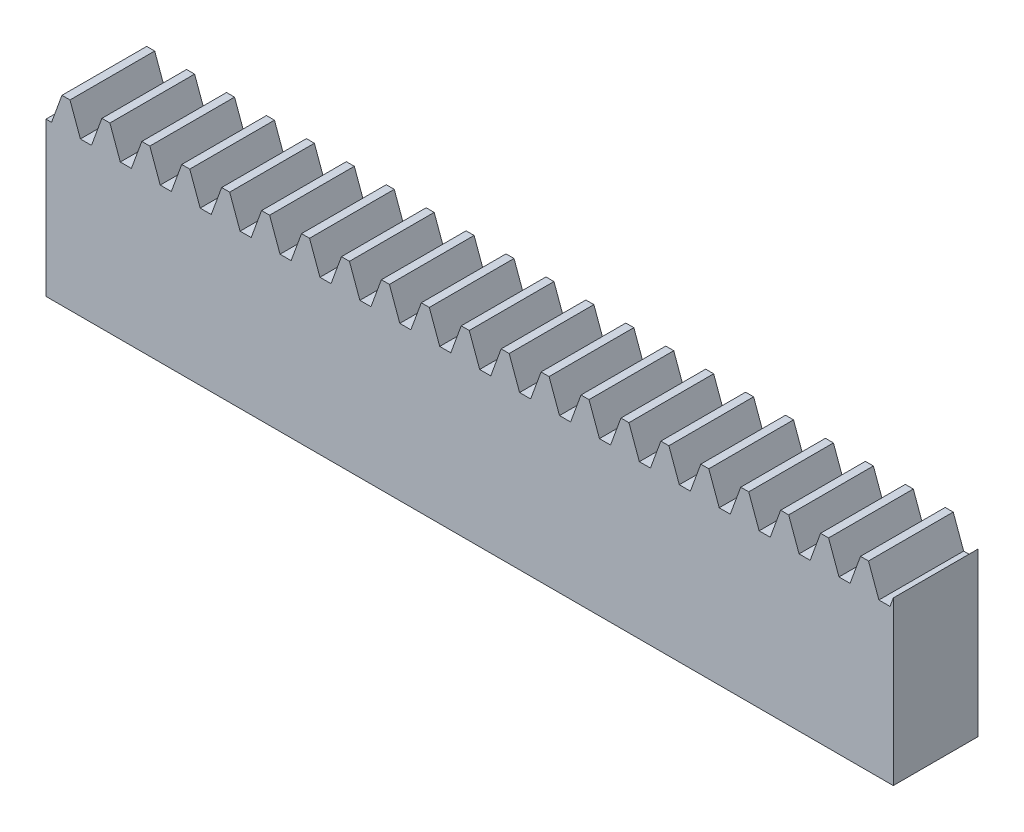
from build123d import *

# Parameters (mm, degrees)
BLANKSKE_W        = 100
BLANKSKE_H        = 21.5
BLANK_DEPTH       = 10
TOOTHCUTSIM_DEPTH = 103.772807688
TEETHCUTS_COUNT   = 22
TEETHCUTS_PITCH   = 4.712388975


with BuildPart() as part:
    # BlankSke → Blank (new body)
    with BuildSketch(Plane.XY):
        with Locations((50, 10.75)):
            Rectangle(BLANKSKE_W, BLANKSKE_H)
    extrude(amount=-BLANK_DEPTH)

    # TooCutSkeSim → ToothCutSim (cut, through all)
    with BuildSketch(Plane.XY):
        Polygon((0.654653055, 18.125), (-0.654653055, 18.125), (-1.892297439, 21.5254), (1.892297439, 21.5254), align=None)
    toothcutsim = extrude(amount=-TOOTHCUTSIM_DEPTH, mode=Mode.SUBTRACT)

    # TeethCuts: ToothCutSim ×22
    with Locations(*[(i * TEETHCUTS_PITCH, 0, 0) for i in range(1, TEETHCUTS_COUNT)]):
        add(toothcutsim, mode=Mode.SUBTRACT)


solid = part.part
